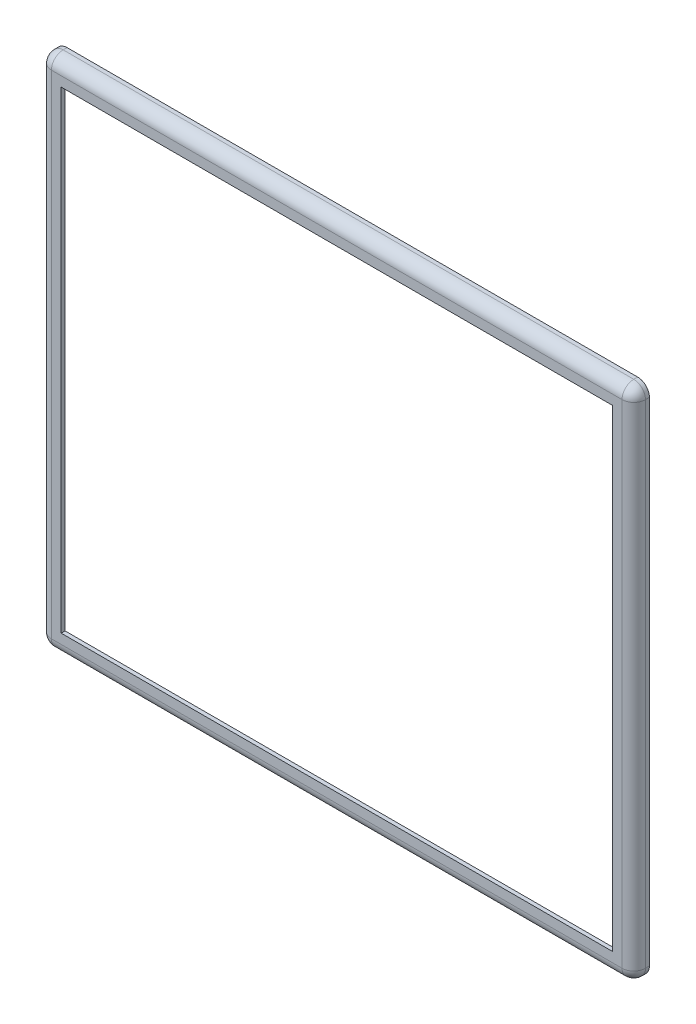
from build123d import *

# Parameters (mm, degrees)
SKETCH1_W           = 152
SKETCH1_H           = 132
SKETCH1_W_2         = 150
SKETCH1_H_2         = 130
BOSS_EXTRUDE1_DEPTH = 3
SKETCH2_W           = 152
SKETCH2_H           = 132
SKETCH2_W_2         = 141
SKETCH2_H_2         = 121
BOSS_EXTRUDE2_DEPTH = 1
FILLET1_R           = 1.4
FILLET2_R           = 3


with BuildPart() as part:
    # Sketch1 → Boss-Extrude1 (new body)
    with BuildSketch(Plane.XY):
        with Locations((-0.37936772, -7.96672213)):
            Rectangle(SKETCH1_W, SKETCH1_H)
        with Locations((-0.37936772, -7.96672213)):
            Rectangle(SKETCH1_W_2, SKETCH1_H_2, mode=Mode.SUBTRACT)
    extrude(amount=BOSS_EXTRUDE1_DEPTH)

    # Sketch2 → Boss-Extrude2 (add)
    with BuildSketch(Plane.XY.offset(3)):
        with Locations((-0.37936772, -7.96672213)):
            Rectangle(SKETCH2_W, SKETCH2_H)
        with Locations((-0.37936772, -7.96672213)):
            Rectangle(SKETCH2_W_2, SKETCH2_H_2, mode=Mode.SUBTRACT)
    extrude(amount=BOSS_EXTRUDE2_DEPTH)

    # Fillet1
    fillet1_edges = [part.edges().sort_by_distance(p)[0] for p in [
        (-75.37936772, 57.03327787, 1.5),
        (-75.37936772, -72.96672213, 1.5),
        (74.62063228, -72.96672213, 1.5),
        (74.62063228, 57.03327787, 1.5),
        (-75.37936772, -7.96672213, 3),
        (-0.37936772, -72.96672213, 3),
        (74.62063228, -7.96672213, 3),
        (-0.37936772, 57.03327787, 3),
    ]]
    fillet(fillet1_edges, radius=FILLET1_R)

    # Fillet2
    fillet2_edges = [part.edges().sort_by_distance(p)[0] for p in [
        (-76.37936772, -7.96672213, 4),
        (-0.37936772, -73.96672213, 4),
        (75.62063228, -7.96672213, 4),
        (-0.37936772, 58.03327787, 4),
        (-76.37936772, 58.03327787, 2),
        (75.62063228, 58.03327787, 2),
        (75.62063228, -73.96672213, 2),
        (-76.37936772, -73.96672213, 2),
    ]]
    fillet(fillet2_edges, radius=FILLET2_R)


solid = part.part
